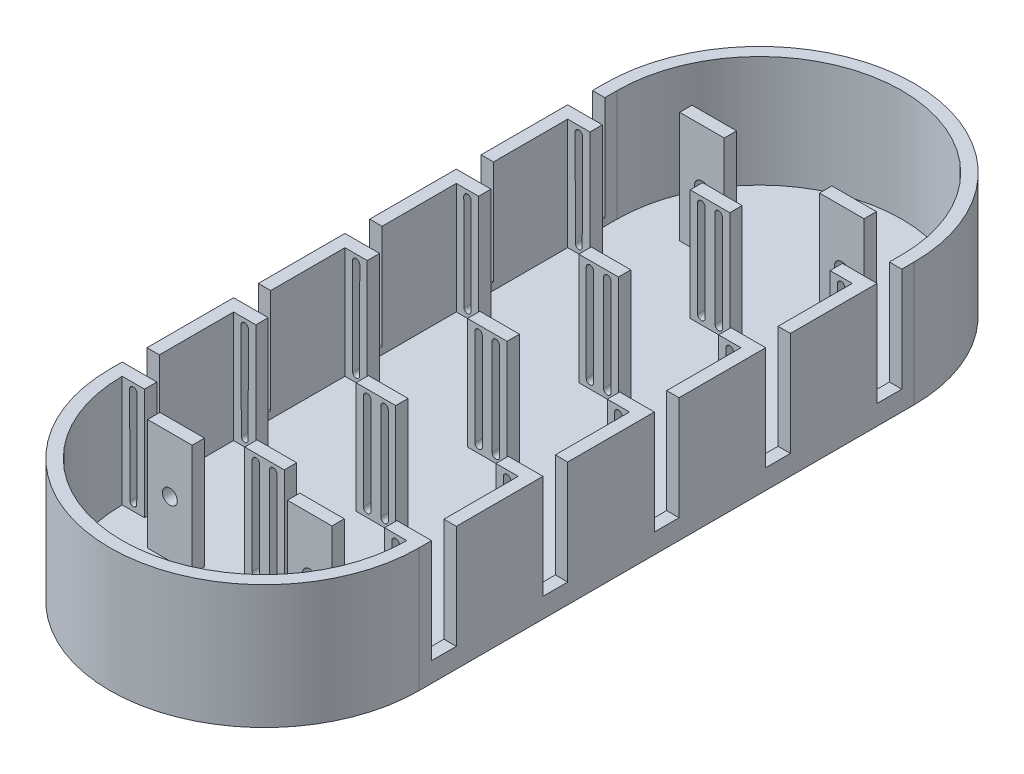
from build123d import *

# Parameters (mm, degrees)
BOSS_EXTRUDE1_DEPTH     = 5
SKETCH3_W               = 9
SKETCH3_H               = 5
SKETCH3_W_2             = 8
BOSS_EXTRUDE3_DEPTH     = 45
CUT_EXTRUDE1_DEPTH      = 192
BOSS_EXTRUDE5_DEPTH     = 45
SKETCH5_W               = 10
SKETCH5_H               = 42
CUT_EXTRUDE2_DEPTH      = 129
BOSS_EXTRUDE6_DEPTH     = 45
SKETCH7_R               = 3
CUT_EXTRUDE4_DEPTH      = 224
CUT_EXTRUDE4_DEPTH_BACK = 9


with BuildPart() as part:
    # Sketch1 → Boss-Extrude1 (new body)
    with BuildSketch(Plane(origin=(0, 0, 0), x_dir=(1, 0, 0), z_dir=(0, 1, 0))):
        with BuildLine():
            Line((-62.5, 200), (-62.5, 0))
            ThreePointArc((-62.5, 0), (0, -62.5), (62.5, 0))
            Line((62.5, 0), (62.5, 200))
            ThreePointArc((62.5, 200), (0, 262.5), (-62.5, 200))
        make_face()
    extrude(amount=BOSS_EXTRUDE1_DEPTH)

    # Sketch3 → Boss-Extrude3 (add)
    with BuildSketch(Plane(origin=(0, 5, 0), x_dir=(1, 0, 0), z_dir=(0, 1, 0))):
        with Locations((-53, 182.5)):
            Rectangle(SKETCH3_W, SKETCH3_H)
        with Locations((-4, 182.5)):
            Rectangle(SKETCH3_W_2, SKETCH3_H)
        with Locations((4, 182.5)):
            Rectangle(SKETCH3_W_2, SKETCH3_H)
        with Locations((53, 182.5)):
            Rectangle(SKETCH3_W, SKETCH3_H)
        with Locations((53, 137.5)):
            Rectangle(SKETCH3_W, SKETCH3_H)
        with Locations((4, 137.5)):
            Rectangle(SKETCH3_W_2, SKETCH3_H)
        with Locations((-4, 137.5)):
            Rectangle(SKETCH3_W_2, SKETCH3_H)
        with Locations((-53, 137.5)):
            Rectangle(SKETCH3_W, SKETCH3_H)
        with Locations((-53, 92.5)):
            Rectangle(SKETCH3_W, SKETCH3_H)
        with Locations((-4, 92.5)):
            Rectangle(SKETCH3_W_2, SKETCH3_H)
        with Locations((4, 92.5)):
            Rectangle(SKETCH3_W_2, SKETCH3_H)
        with Locations((53, 92.5)):
            Rectangle(SKETCH3_W, SKETCH3_H)
        with Locations((-53, 47.5)):
            Rectangle(SKETCH3_W, SKETCH3_H)
        with Locations((-4, 47.5)):
            Rectangle(SKETCH3_W_2, SKETCH3_H)
        with Locations((4, 47.5)):
            Rectangle(SKETCH3_W_2, SKETCH3_H)
        with Locations((53, 47.5)):
            Rectangle(SKETCH3_W, SKETCH3_H)
        with Locations((53, 2.5)):
            Rectangle(SKETCH3_W, SKETCH3_H)
        with Locations((4, 2.5)):
            Rectangle(SKETCH3_W_2, SKETCH3_H)
        with Locations((-4, 2.5)):
            Rectangle(SKETCH3_W_2, SKETCH3_H)
        with Locations((-53, 2.5)):
            Rectangle(SKETCH3_W, SKETCH3_H)
    extrude(amount=BOSS_EXTRUDE3_DEPTH)

    # Sketch4 → Cut-Extrude1 (cut)
    with BuildSketch(Plane.XY):
        with BuildLine():
            Line((-54.36982713, 8), (-54.5, 47))
            ThreePointArc((-54.5, 47), (-53, 48.5), (-51.5, 47))
            Line((-51.5, 47), (-51.63017287, 8))
            ThreePointArc((-51.63017287, 8), (-53, 6.63017287), (-54.36982713, 8))
        make_face()
        with BuildLine():
            Line((-5, 8), (-5, 47))
            ThreePointArc((-5, 47), (-3.5, 48.5), (-2, 47))
            Line((-2, 47), (-2, 8))
            ThreePointArc((-2, 8), (-3.5, 6.5), (-5, 8))
        make_face()
        with BuildLine():
            Line((2, 47), (2, 8))
            ThreePointArc((2, 8), (3.5, 6.5), (5, 8))
            Line((5, 8), (5, 47))
            ThreePointArc((5, 47), (3.5, 48.5), (2, 47))
        make_face()
        with BuildLine():
            Line((51.5, 47), (51.63017287, 8))
            ThreePointArc((51.63017287, 8), (53, 6.63017287), (54.36982713, 8))
            Line((54.36982713, 8), (54.5, 47))
            ThreePointArc((54.5, 47), (53, 48.5), (51.5, 47))
        make_face()
    extrude(amount=-CUT_EXTRUDE1_DEPTH, mode=Mode.SUBTRACT)

    # Sketch2 → Boss-Extrude5 (add)
    with BuildSketch(Plane(origin=(0, 5, 0), x_dir=(1, 0, 0), z_dir=(0, 1, 0))):
        with BuildLine():
            Line((-62.5, 200), (-62.5, 0))
            ThreePointArc((-62.5, 0), (0, -62.5), (62.5, 0))
            Line((62.5, 0), (62.5, 200))
            ThreePointArc((62.5, 200), (0, 262.5), (-62.5, 200))
        make_face()
        with BuildLine():
            Line((-57.5, 200), (-57.5, 0))
            ThreePointArc((-57.5, 0), (0, -57.5), (57.5, 0))
            Line((57.5, 0), (57.5, 200))
            ThreePointArc((57.5, 200), (0, 257.5), (-57.5, 200))
        make_face(mode=Mode.SUBTRACT)
    extrude(amount=BOSS_EXTRUDE5_DEPTH)

    # Sketch5 → Cut-Extrude2 (cut)
    with BuildSketch(Plane.ZY.offset(62.5)):
        with Locations((-190, 29)):
            Rectangle(SKETCH5_W, SKETCH5_H)
        with Locations((-145, 29)):
            Rectangle(SKETCH5_W, SKETCH5_H)
        with Locations((-100, 29)):
            Rectangle(SKETCH5_W, SKETCH5_H)
        with Locations((-55, 29)):
            Rectangle(SKETCH5_W, SKETCH5_H)
        with Locations((-10, 29)):
            Rectangle(SKETCH5_W, SKETCH5_H)
    extrude(amount=-CUT_EXTRUDE2_DEPTH, mode=Mode.SUBTRACT)

    # Sketch6 → Boss-Extrude6 (add)
    with BuildSketch(Plane(origin=(0, 5, 0), x_dir=(1, 0, 0), z_dir=(0, 1, 0))):
        Polygon((-28.25, 205), (-37.25, 205), (-37.25, 210), (-19.25, 210), (-19.25, 205), align=None)
        Polygon((28.25, 205), (19.25, 205), (19.25, 210), (37.25, 210), (37.25, 205), align=None)
        Polygon((37.25, -10), (37.25, -5), (28.25, -5), (19.25, -5), (19.25, -10), align=None)
        Polygon((-19.25, -10), (-19.25, -5), (-28.25, -5), (-37.25, -5), (-37.25, -10), align=None)
    extrude(amount=BOSS_EXTRUDE6_DEPTH)

    # Sketch7 → Cut-Extrude4 (cut, two sides)
    with BuildSketch(Plane.XY.offset(-205)) as cut_extrude4_sk:
        with Locations((-28.25, 27.5)):
            Circle(SKETCH7_R)
        with Locations((28.25, 27.5)):
            Circle(SKETCH7_R)
    extrude(amount=CUT_EXTRUDE4_DEPTH, mode=Mode.SUBTRACT)
    extrude(cut_extrude4_sk.sketch, amount=-CUT_EXTRUDE4_DEPTH_BACK, mode=Mode.SUBTRACT)


solid = part.part
